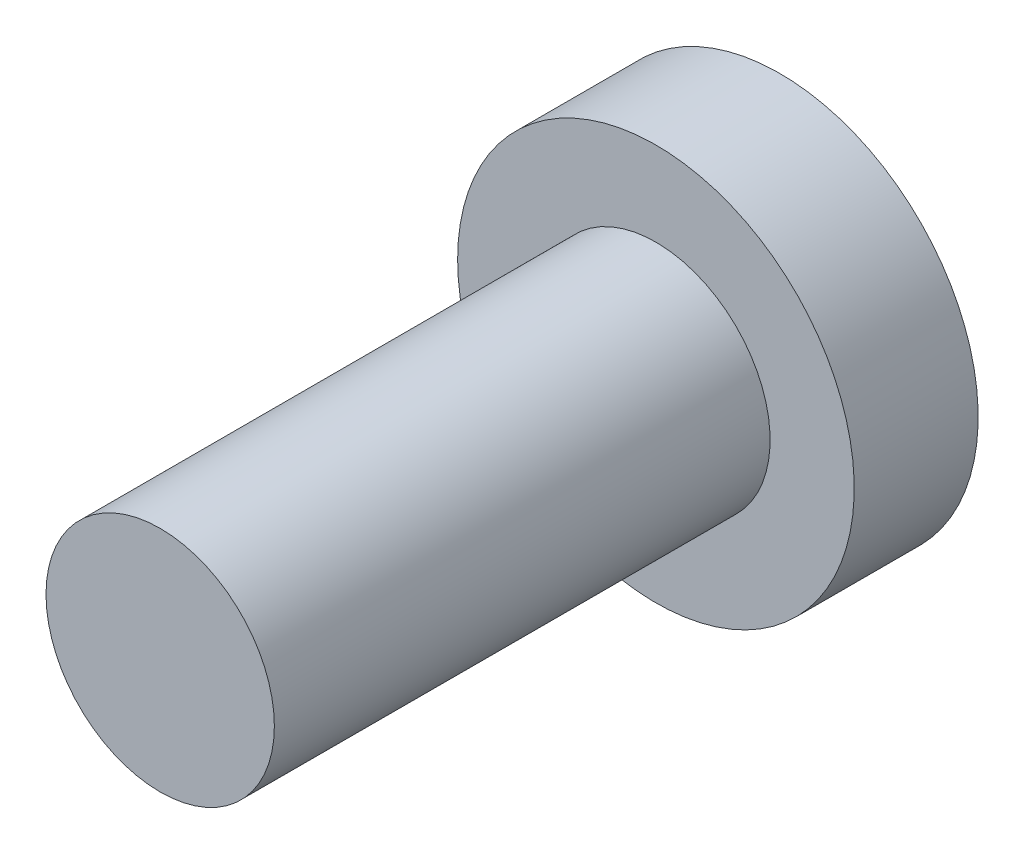
from build123d import *

# Parameters (mm, degrees)
SKETCH1_R           = 3.175
BOSS_EXTRUDE1_DEPTH = 12.7
SKETCH2_R           = 5.08
BOSS_EXTRUDE2_DEPTH = 3.175
MOVE_FACE1_BY       = 0.250000008


with BuildPart() as part:
    # Sketch1 → Boss-Extrude1 (new body)
    with BuildSketch(Plane.XY):
        Circle(SKETCH1_R)
    extrude(amount=BOSS_EXTRUDE1_DEPTH)

    # Sketch2 → Boss-Extrude2 (add)
    with BuildSketch(Plane(origin=(0, 0, 0), x_dir=(-1, 0, 0), z_dir=(0, 0, -1))):
        Circle(SKETCH2_R)
    extrude(amount=BOSS_EXTRUDE2_DEPTH)

    # Move Face1: a curved face moved inward by 0.25
    add(Solid.thicken(part.faces().sort_by_distance((-3.175, 0, 6.35))[0], -MOVE_FACE1_BY), mode=Mode.SUBTRACT)


solid = part.part
